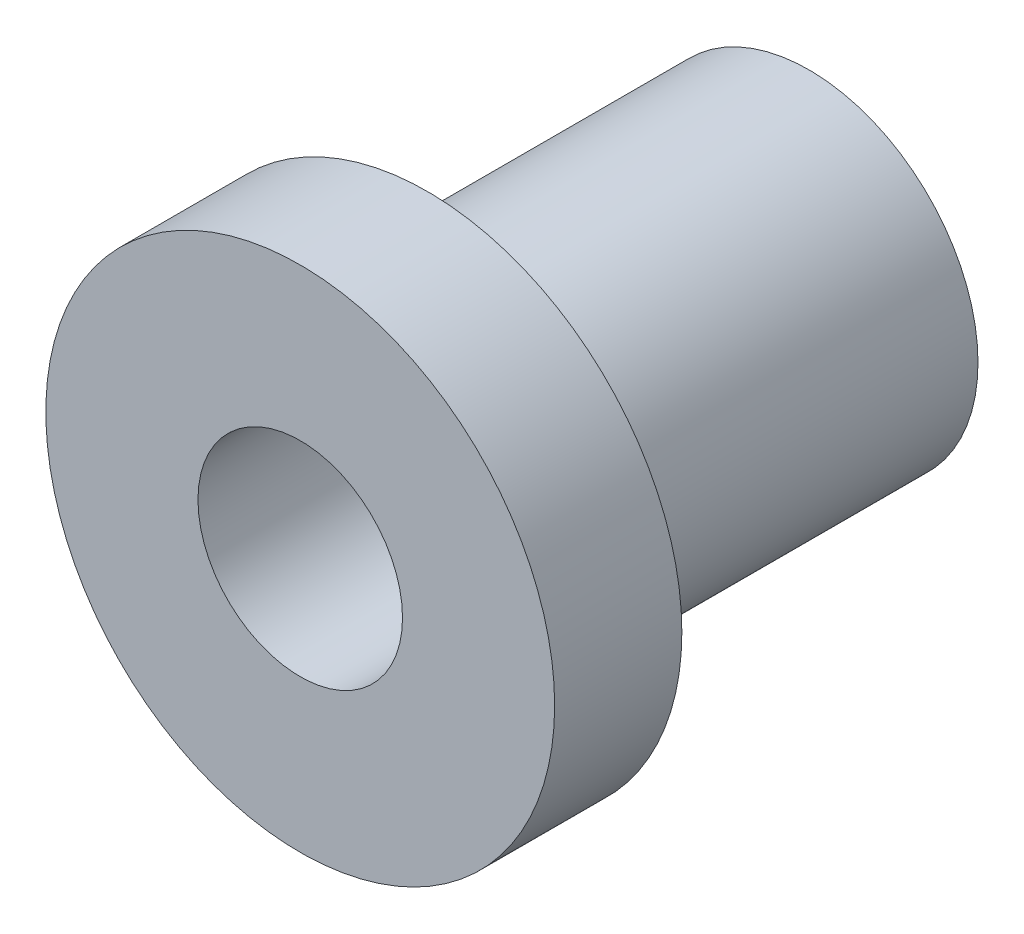
from build123d import *

# Parameters (mm, degrees)
SKETCH1_R           = 4.2164
BOSS_EXTRUDE1_DEPTH = 9.525
SKETCH2_R           = 6.35
BOSS_EXTRUDE2_DEPTH = 3.175
SKETCH3_R           = 2.5527
CUT_EXTRUDE1_DEPTH  = 13.7


with BuildPart() as part:
    # Sketch1 → Boss-Extrude1 (new body)
    with BuildSketch(Plane.XY):
        Circle(SKETCH1_R)
    extrude(amount=BOSS_EXTRUDE1_DEPTH)

    # Sketch2 → Boss-Extrude2 (add)
    with BuildSketch(Plane.XY.offset(9.525)):
        Circle(SKETCH2_R)
    extrude(amount=BOSS_EXTRUDE2_DEPTH)

    # Sketch3 → Cut-Extrude1 (cut, through all)
    with BuildSketch(Plane.XY.offset(12.7)):
        Circle(SKETCH3_R)
    extrude(amount=-CUT_EXTRUDE1_DEPTH, mode=Mode.SUBTRACT)


solid = part.part
